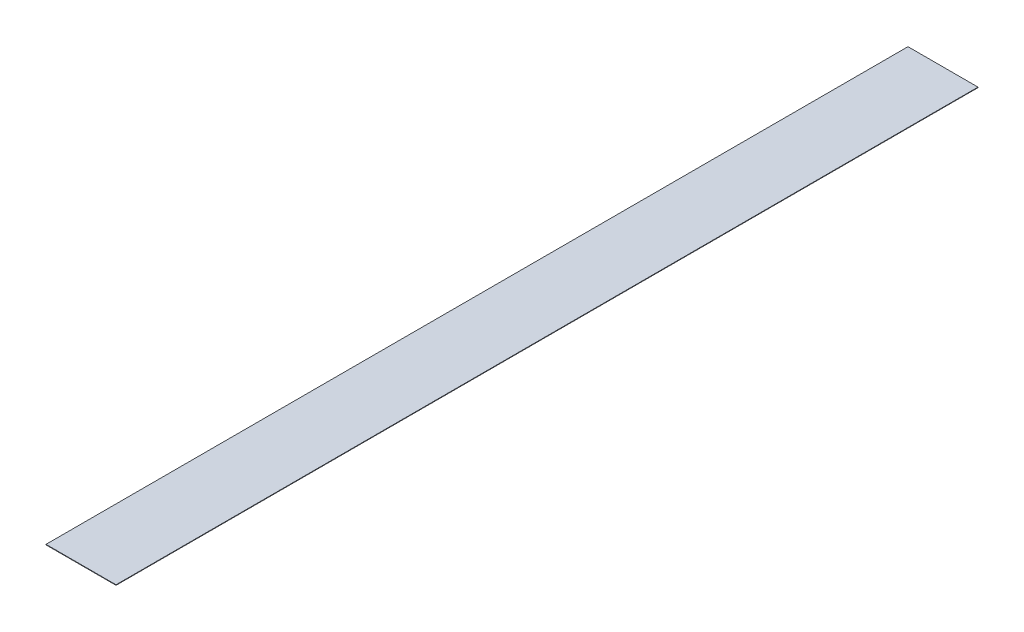
from build123d import *

# Parameters (mm, degrees)
SKETCH1_W      = 24.9
SKETCH1_H      = 306.5
EXTRUDE1_DEPTH = 0.175


with BuildPart() as part:
    # Sketch1 → Extrude1 (new body)
    with BuildSketch(Plane(origin=(0, 0, 0), x_dir=(1, 0, 0), z_dir=(0, 1, 0))):
        Rectangle(SKETCH1_W, SKETCH1_H)
    extrude(amount=EXTRUDE1_DEPTH)


solid = part.part
